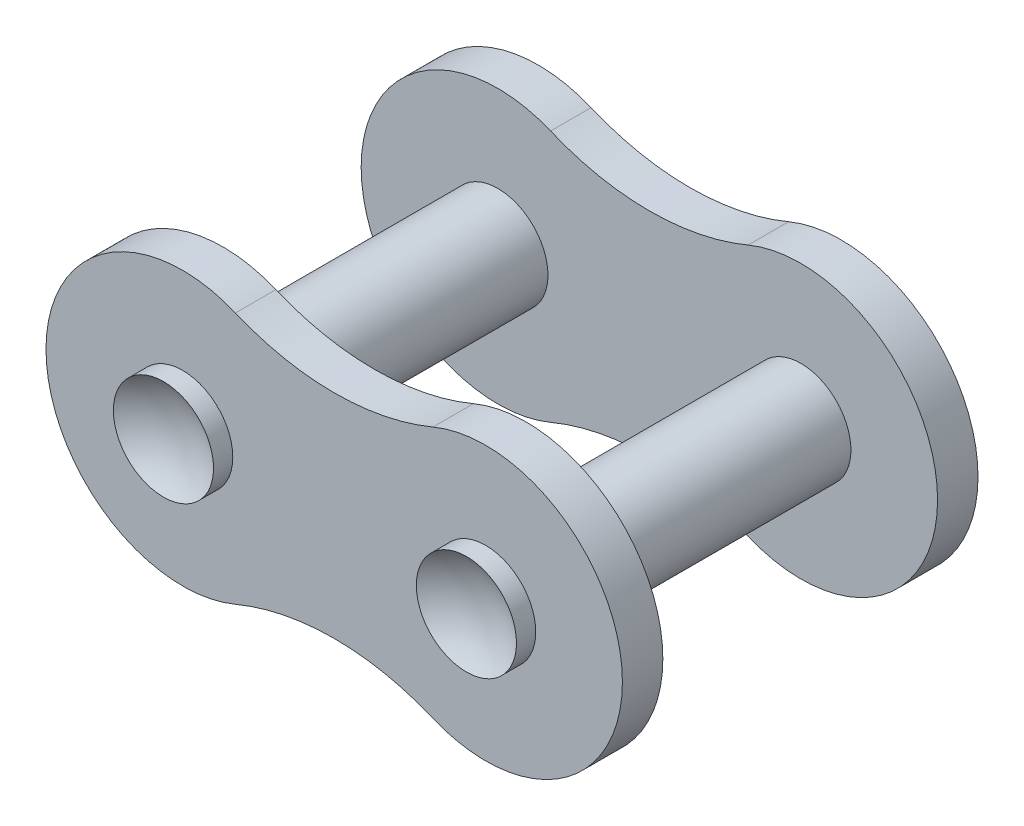
from build123d import *

# Parameters (mm, degrees)
SKETCH3_R             = 1.9812
BOSS_EXTRUDE1_DEPTH   = 7.7978
BOSS_EXTRUDE1_2_DEPTH = 7.7978
BOSS_EXTRUDE2_DEPTH   = 1.6002


with BuildPart() as part:
    # Sketch3 → Boss-Extrude1 (new body, symmetric)
    with BuildSketch(Plane.XY):
        with Locations((-5.9944, 0)):
            Circle(SKETCH3_R)
    extrude(amount=BOSS_EXTRUDE1_DEPTH, both=True)



with BuildPart() as body_2:
    # Sketch3 → Boss-Extrude1 2 (new body, symmetric)
    with BuildSketch(Plane.XY):
        with Locations((5.9944, 0)):
            Circle(SKETCH3_R)
    extrude(amount=BOSS_EXTRUDE1_2_DEPTH, both=True)


with BuildPart() as part_1:
    add(part.part)

    add(body_2.part)  # Boss-Extrude2 merges body 2
    # Sketch4 → Boss-Extrude2 (add)
    with BuildSketch(Plane.XY.offset(7.0358)):
        with BuildLine():
            ThreePointArc((-3.908114, 4.991761), (-11.4046, 0), (-3.908114, -4.991761))
            ThreePointArc((-3.908114, -4.991761), (0, -4.207923), (3.908114, -4.991761))
            ThreePointArc((3.908114, -4.991761), (11.4046, 0), (3.908114, 4.991761))
            ThreePointArc((3.908114, 4.991761), (0, 4.207923), (-3.908114, 4.991761))
        make_face()
    boss_extrude2 = extrude(amount=-BOSS_EXTRUDE2_DEPTH)

    # Mirror1: Boss-Extrude2 across plane
    add(boss_extrude2.mirror(Plane.XY))

    # Sketch5 → Cut-Revolve1 (revolve, cut)
    with BuildSketch(Plane(origin=(0, 0, 0), x_dir=(1, 0, 0), z_dir=(0, 1, 0))):
        with BuildLine():
            Line((-5.9944, 7.7978), (-5.9944, 7.1374))
            ThreePointArc((-5.9944, 7.1374), (-4.950216, 7.306848), (-4.0132, 7.7978))
            Line((-4.0132, 7.7978), (-5.9944, 7.7978))
        make_face()
        with BuildLine():
            Line((-5.9944, -7.1374), (-5.9944, -7.7978))
            Line((-5.9944, -7.7978), (-4.0132, -7.7978))
            ThreePointArc((-4.0132, -7.7978), (-4.950216, -7.306848), (-5.9944, -7.1374))
        make_face()
    cut_revolve1 = revolve(axis=Axis((-5.9944, 0, 7.7978), (0, 0, -1)), mode=Mode.SUBTRACT)

    # Mirror2: Cut-Revolve1 across plane
    add(cut_revolve1.mirror(Plane(origin=(0, 0, 0), x_dir=(0, 0, 1), z_dir=(1, 0, 0))), mode=Mode.SUBTRACT)


solid = part_1.part
